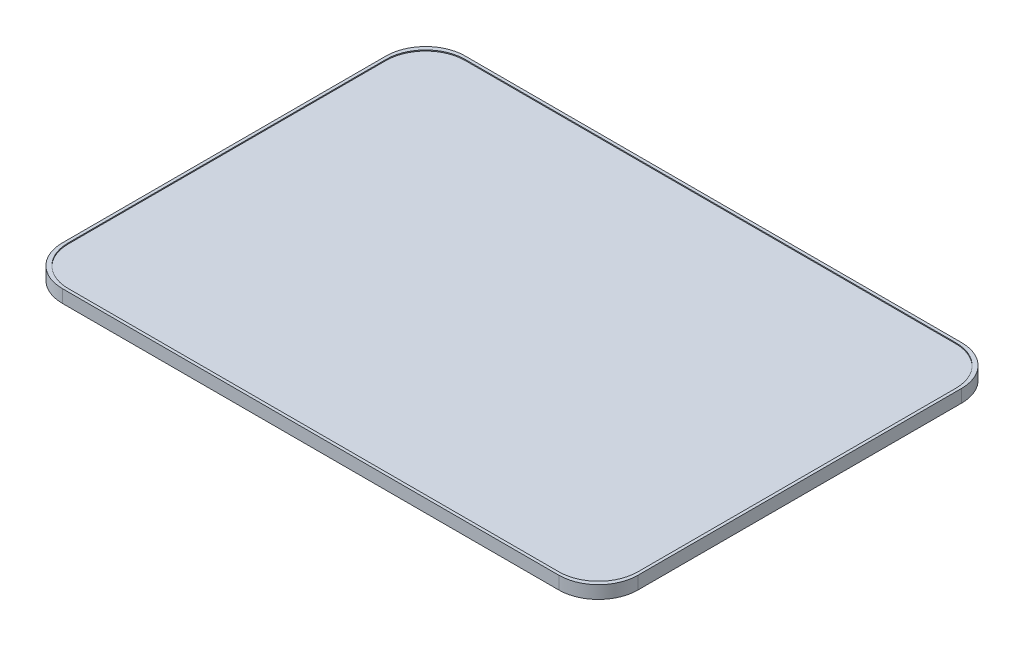
from build123d import *

# Parameters (mm, degrees)
SKETCH1_W           = 583
SKETCH1_H           = 408
BOSS_EXTRUDE1_DEPTH = 11
SKETCH2_W           = 583
SKETCH2_H           = 408
SKETCH2_W_2         = 577
SKETCH2_H_2         = 402
BOSS_EXTRUDE2_DEPTH = 1
SKETCH3_W           = 583
SKETCH3_H           = 408
SKETCH3_W_2         = 577
SKETCH3_H_2         = 402
BOSS_EXTRUDE3_DEPTH = 1
FILLET2_R           = 40


with BuildPart() as part:
    # Sketch1 → Boss-Extrude1 (new body)
    with BuildSketch(Plane(origin=(0, 0, 0), x_dir=(1, 0, 0), z_dir=(0, 1, 0))):
        Rectangle(SKETCH1_W, SKETCH1_H)
    extrude(amount=BOSS_EXTRUDE1_DEPTH)

    # Sketch2 → Boss-Extrude2 (add)
    with BuildSketch(Plane(origin=(0, 11, 0), x_dir=(1, 0, 0), z_dir=(0, 1, 0))):
        Rectangle(SKETCH2_W, SKETCH2_H)
        Rectangle(SKETCH2_W_2, SKETCH2_H_2, mode=Mode.SUBTRACT)
    extrude(amount=BOSS_EXTRUDE2_DEPTH)

    # Sketch3 → Boss-Extrude3 (add)
    with BuildSketch(Plane.XZ):
        Rectangle(SKETCH3_W, SKETCH3_H)
        Rectangle(SKETCH3_W_2, SKETCH3_H_2, mode=Mode.SUBTRACT)
    extrude(amount=BOSS_EXTRUDE3_DEPTH)

    # Fillet2
    fillet2_edges = [part.edges().sort_by_distance(p)[0] for p in [
        (-288.5, 11.5, 201),
        (288.5, 11.5, 201),
        (288.5, 11.5, -201),
        (-288.5, 11.5, -201),
        (-288.5, -0.5, -201),
        (288.5, -0.5, -201),
        (288.5, -0.5, 201),
        (-288.5, -0.5, 201),
        (291.5, 5.5, 204),
        (-291.5, 5.5, 204),
        (-291.5, 5.5, -204),
        (291.5, 5.5, -204),
    ]]
    fillet(fillet2_edges, radius=FILLET2_R)


solid = part.part
